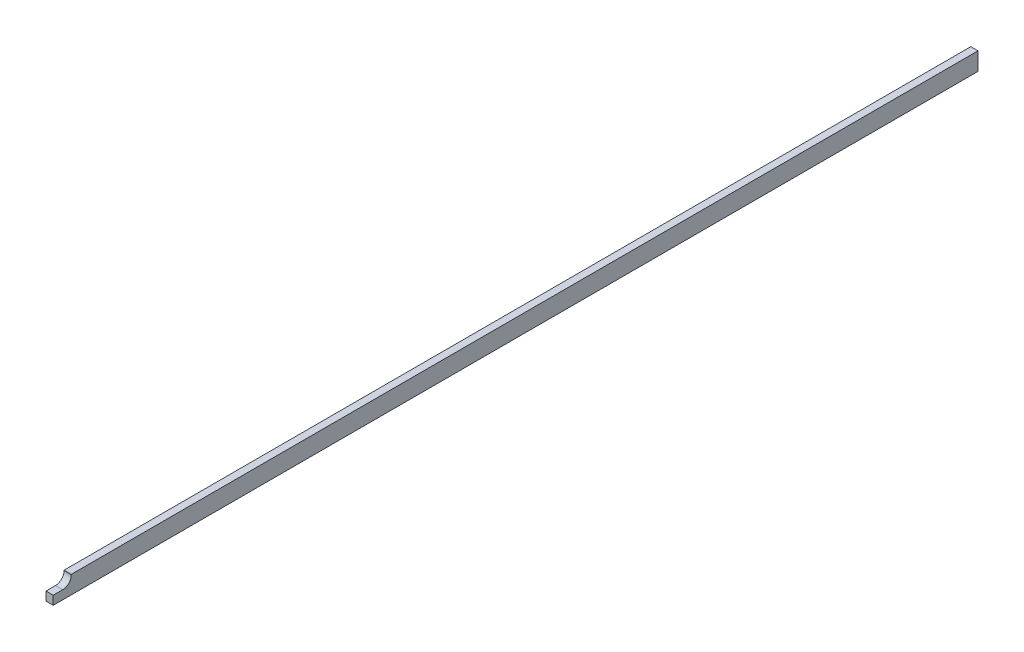
from build123d import *

# Parameters (mm, degrees)
SKETCH1_W           = 1.6
SKETCH1_H           = 3.95
BOSS_EXTRUDE1_DEPTH = 205
CUT_EXTRUDE1_DEPTH  = 205


with BuildPart() as part:
    # Sketch1 → Boss-Extrude1 (new body)
    with BuildSketch(Plane.XY):
        Rectangle(SKETCH1_W, SKETCH1_H)
    extrude(amount=BOSS_EXTRUDE1_DEPTH)

    # Sketch2 → Cut-Extrude1 (cut)
    with BuildSketch(Plane(origin=(0.8, 0, 0), x_dir=(0, 0, -1), z_dir=(1, 0, 0))):
        with BuildLine():
            Line((-205, 1.975), (-201, 1.975))
            Line((-201, 1.975), (-201, 1.875))
            ThreePointArc((-201, 1.875), (-201.556497116, 0.531497116), (-202.9, -0.025))
            Line((-202.9, -0.025), (-205, -0.025))
            Line((-205, -0.025), (-205, 1.975))
        make_face()
    extrude(amount=-CUT_EXTRUDE1_DEPTH, mode=Mode.SUBTRACT)


solid = part.part
